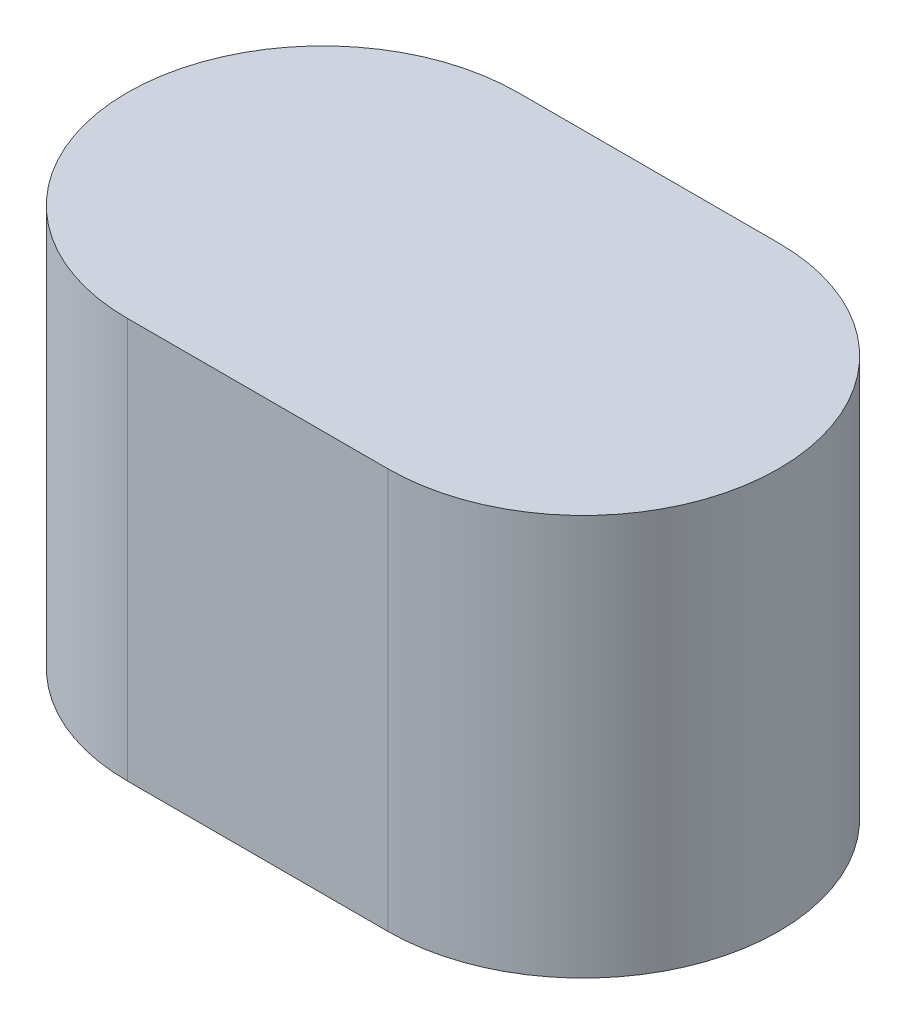
from build123d import *

# Parameters (mm, degrees)
BOSS_EXTRUDE1_DEPTH = 6.15


with BuildPart() as part:
    # Sketch1 → Boss-Extrude1 (new body)
    with BuildSketch(Plane(origin=(0, 0, 0), x_dir=(1, 0, 0), z_dir=(0, 1, 0))):
        with BuildLine():
            Line((0, 3), (4, 3))
            ThreePointArc((4, 3), (7, 0), (4, -3))
            Line((4, -3), (0, -3))
            ThreePointArc((0, -3), (-3, 0), (0, 3))
        make_face()
    extrude(amount=BOSS_EXTRUDE1_DEPTH)


solid = part.part
